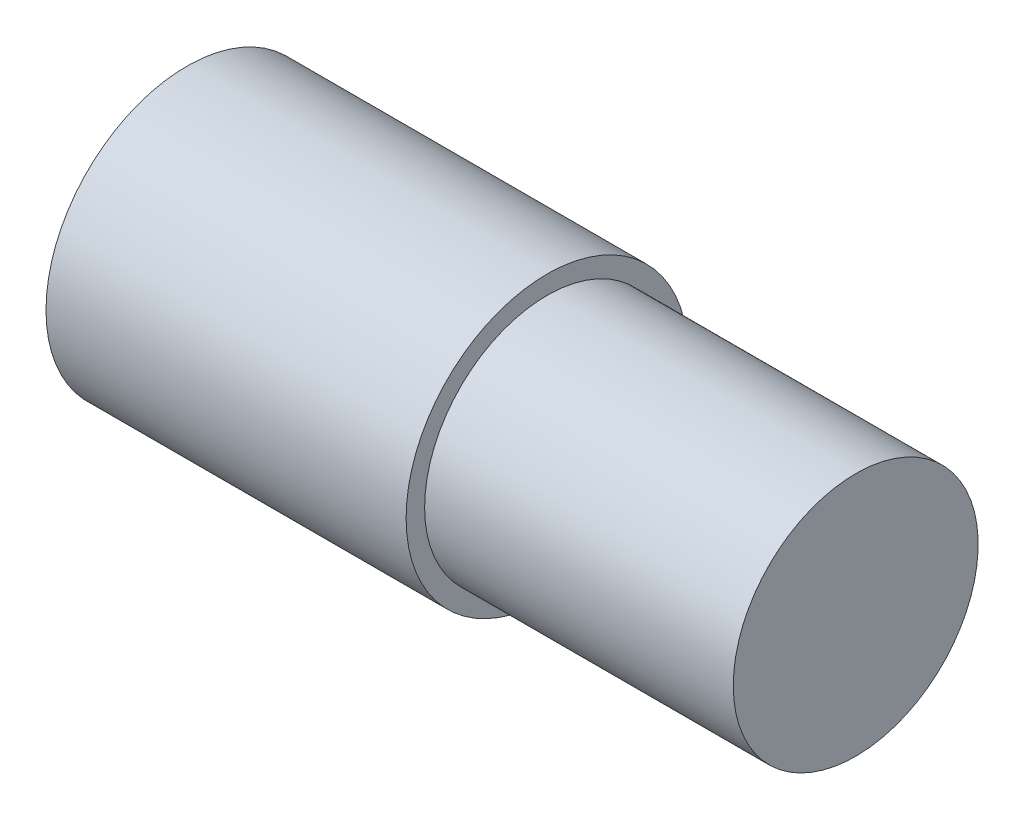
from build123d import *


with BuildPart() as part:
    # Sketch1 → Revolve1 (revolve)
    with BuildSketch(Plane.XY):
        Polygon((44.45, 17.399), (44.45, 15.113), (82.55, 15.113), (82.55, 0), (0, 0), (0, 17.399), align=None)
    revolve(axis=Axis((-28.99068001, 0, 0), (1, 0, 0)))


solid = part.part
